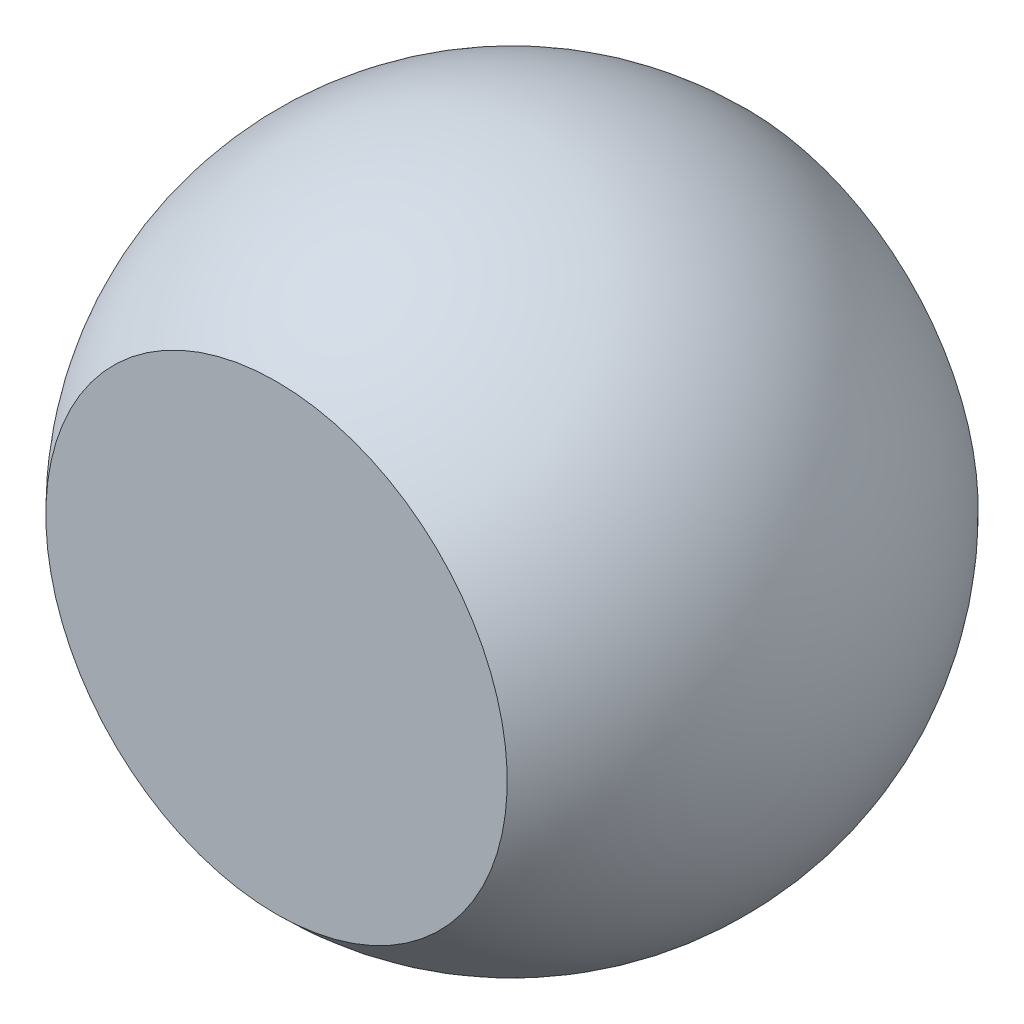
from build123d import *

# Parameters (mm, degrees)
SKETCH2_W          = 0.2
SKETCH2_H          = 1.233474408
CUT_EXTRUDE1_DEPTH = 5


with BuildPart() as part:
    # Sketch1 → Revolve3 (revolve)
    with BuildSketch(Plane(origin=(0, 0, 0), x_dir=(1, 0, 0), z_dir=(0, 1, 0))):
        with BuildLine():
            Line((0, 0.35), (0, -0.35))
            ThreePointArc((0, -0.35), (-0.35, 0), (0, 0.35))
        make_face()
    revolve(axis=Axis((0, 0, -0.35), (0, 0, 1)))

    # Sketch2 → Cut-Extrude1 (cut, symmetric)
    with BuildSketch(Plane(origin=(0, 0, 0), x_dir=(0, 0, -1), z_dir=(1, 0, 0))):
        with Locations((0.35, -0.006283266)):
            Rectangle(SKETCH2_W, SKETCH2_H)
    cut_extrude1 = extrude(amount=CUT_EXTRUDE1_DEPTH, both=True, mode=Mode.SUBTRACT)

    # Mirror1: Cut-Extrude1 across plane
    add(cut_extrude1.mirror(Plane.XY), mode=Mode.SUBTRACT)


solid = part.part
